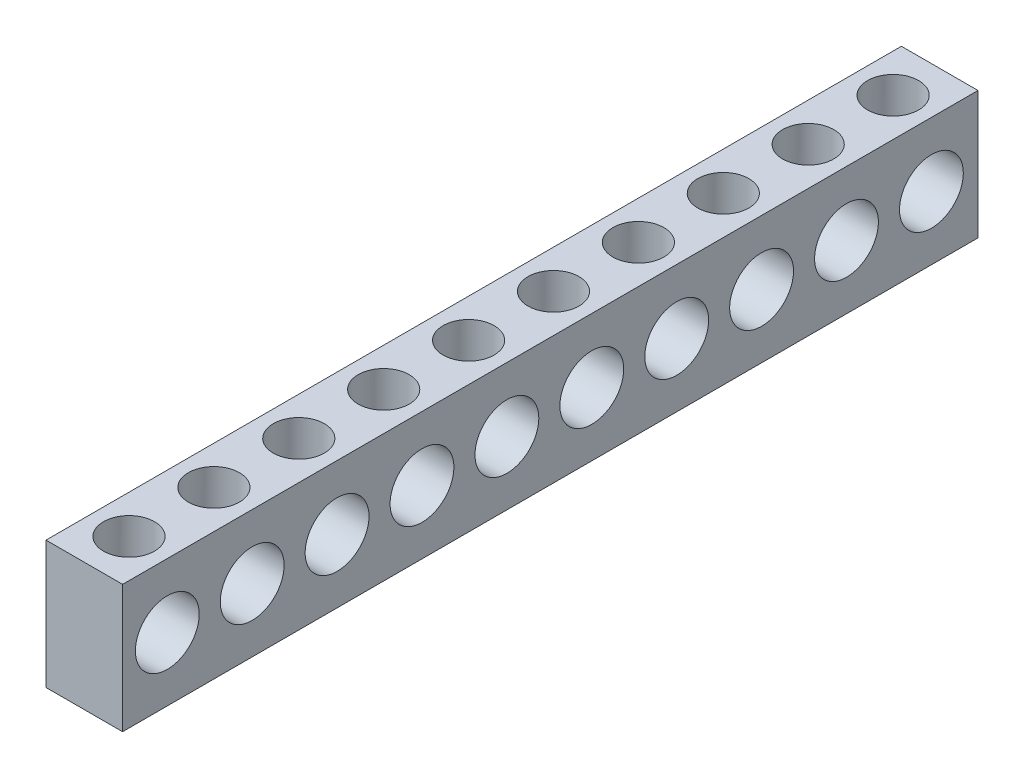
from build123d import *

# Parameters (mm, degrees)
ESBO_O1_W                = 6
ESBO_O1_H                = 10
RESSALTO_EXTRUS_O1_DEPTH = 67
ESBO_O2_R                = 2.5
CORTE_EXTRUS_O1_DEPTH    = 67
ESBO_O3_R                = 2
CORTE_EXTRUS_O2_DEPTH    = 6


with BuildPart() as part:
    # Esboço1 → Ressalto-extrusão1 (new body)
    with BuildSketch(Plane.XY):
        with Locations((-3, 5)):
            Rectangle(ESBO_O1_W, ESBO_O1_H)
    extrude(amount=RESSALTO_EXTRUS_O1_DEPTH)

    # Esboço2 → Corte-extrusão1 (cut)
    with BuildSketch(Plane(origin=(0, 0, 0), x_dir=(0, 0, -1), z_dir=(1, 0, 0))):
        with Locations((-63.5, 4.977459114)):
            Circle(ESBO_O2_R)
        with Locations((-56.85, 4.977459114)):
            Circle(ESBO_O2_R)
        with Locations((-50.2, 4.977459114)):
            Circle(ESBO_O2_R)
        with Locations((-43.55, 4.977459114)):
            Circle(ESBO_O2_R)
        with Locations((-36.9, 4.977459114)):
            Circle(ESBO_O2_R)
        with Locations((-30.25, 4.977459114)):
            Circle(ESBO_O2_R)
        with Locations((-23.6, 4.977459114)):
            Circle(ESBO_O2_R)
        with Locations((-16.95, 4.977459114)):
            Circle(ESBO_O2_R)
        with Locations((-10.3, 4.977459114)):
            Circle(ESBO_O2_R)
        with Locations((-3.65, 4.977459114)):
            Circle(ESBO_O2_R)
    extrude(amount=-CORTE_EXTRUS_O1_DEPTH, mode=Mode.SUBTRACT)

    # Esboço3 → Corte-extrusão2 (cut)
    with BuildSketch(Plane(origin=(0, 10, 0), x_dir=(1, 0, 0), z_dir=(0, 1, 0))):
        with Locations((-3, -63.5)):
            Circle(ESBO_O3_R)
        with Locations((-3, -56.85)):
            Circle(ESBO_O3_R)
        with Locations((-3, -50.2)):
            Circle(ESBO_O3_R)
        with Locations((-3, -43.55)):
            Circle(ESBO_O3_R)
        with Locations((-3, -36.9)):
            Circle(ESBO_O3_R)
        with Locations((-3, -30.25)):
            Circle(ESBO_O3_R)
        with Locations((-3, -23.6)):
            Circle(ESBO_O3_R)
        with Locations((-3, -16.95)):
            Circle(ESBO_O3_R)
        with Locations((-3, -10.3)):
            Circle(ESBO_O3_R)
        with Locations((-3, -3.65)):
            Circle(ESBO_O3_R)
    extrude(amount=-CORTE_EXTRUS_O2_DEPTH, mode=Mode.SUBTRACT)


solid = part.part
